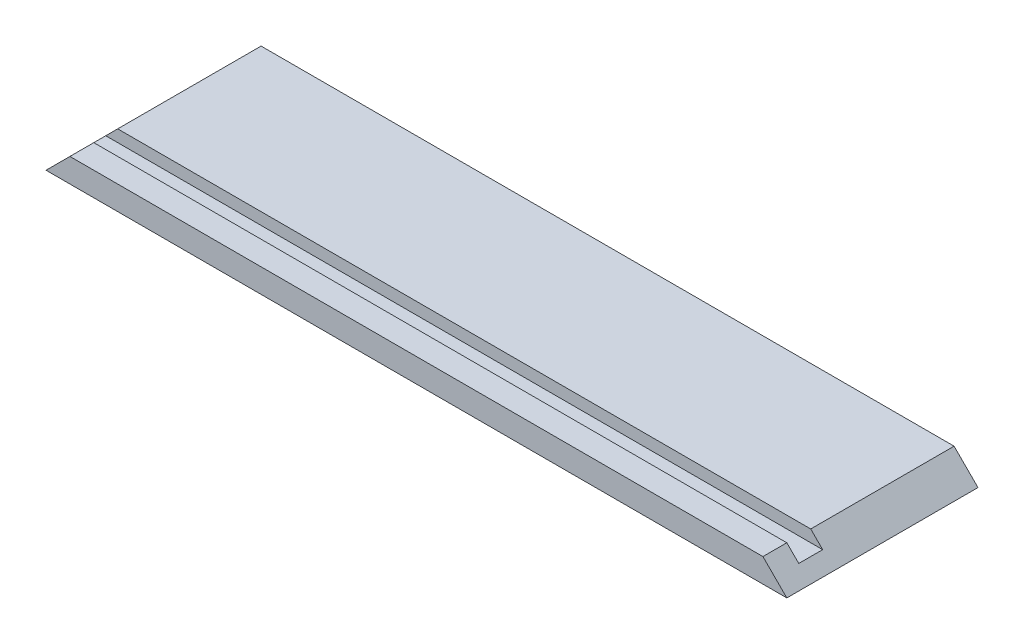
from build123d import *

# Parameters (mm, degrees)
SKETCH1_W               = 196.85
SKETCH1_H               = 50.8
BOSS_EXTRUDE1_DEPTH     = 6.35
SKETCH4_W               = 196.85
SKETCH4_H               = 6.35
CUT_EXTRUDE3_DEPTH      = 3.175
CUT_EXTRUDE1_DEPTH      = 1
CUT_EXTRUDE1_DEPTH_BACK = 51.8
CUT_EXTRUDE2_DEPTH      = 1
CUT_EXTRUDE2_DEPTH_BACK = 51.8


with BuildPart() as part:
    # Sketch1 → Boss-Extrude1 (new body)
    with BuildSketch(Plane(origin=(0, 0, 0), x_dir=(1, 0, 0), z_dir=(0, 1, 0))):
        Rectangle(SKETCH1_W, SKETCH1_H)
    extrude(amount=BOSS_EXTRUDE1_DEPTH)

    # Sketch4 → Cut-Extrude3 (cut)
    with BuildSketch(Plane(origin=(0, 6.35, 0), x_dir=(1, 0, 0), z_dir=(0, 1, 0))):
        with Locations((0, -15.875)):
            Rectangle(SKETCH4_W, SKETCH4_H)
    extrude(amount=-CUT_EXTRUDE3_DEPTH, mode=Mode.SUBTRACT)

    # Sketch2 → Cut-Extrude1 (cut, two sides)
    with BuildSketch(Plane.XY.offset(25.4)) as cut_extrude1_sk:
        Polygon((-384.028812745, -285.603812745), (-98.425, 0), (-92.075, 6.35), (193.528812745, 291.953812745), (-377.678812745, 863.161438235), (-955.236438235, 285.603812745), align=None)
    extrude(amount=CUT_EXTRUDE1_DEPTH, mode=Mode.SUBTRACT)
    extrude(cut_extrude1_sk.sketch, amount=-CUT_EXTRUDE1_DEPTH_BACK, mode=Mode.SUBTRACT)

    # Sketch3 → Cut-Extrude2 (cut, two sides)
    with BuildSketch(Plane.XY.offset(25.4)) as cut_extrude2_sk:
        Polygon((384.028812745, -285.603812745), (98.425, 0), (92.075, 6.35), (-193.528812745, 291.953812745), (377.678812745, 863.161438235), (955.236438235, 285.603812745), align=None)
    extrude(amount=CUT_EXTRUDE2_DEPTH, mode=Mode.SUBTRACT)
    extrude(cut_extrude2_sk.sketch, amount=-CUT_EXTRUDE2_DEPTH_BACK, mode=Mode.SUBTRACT)


solid = part.part
